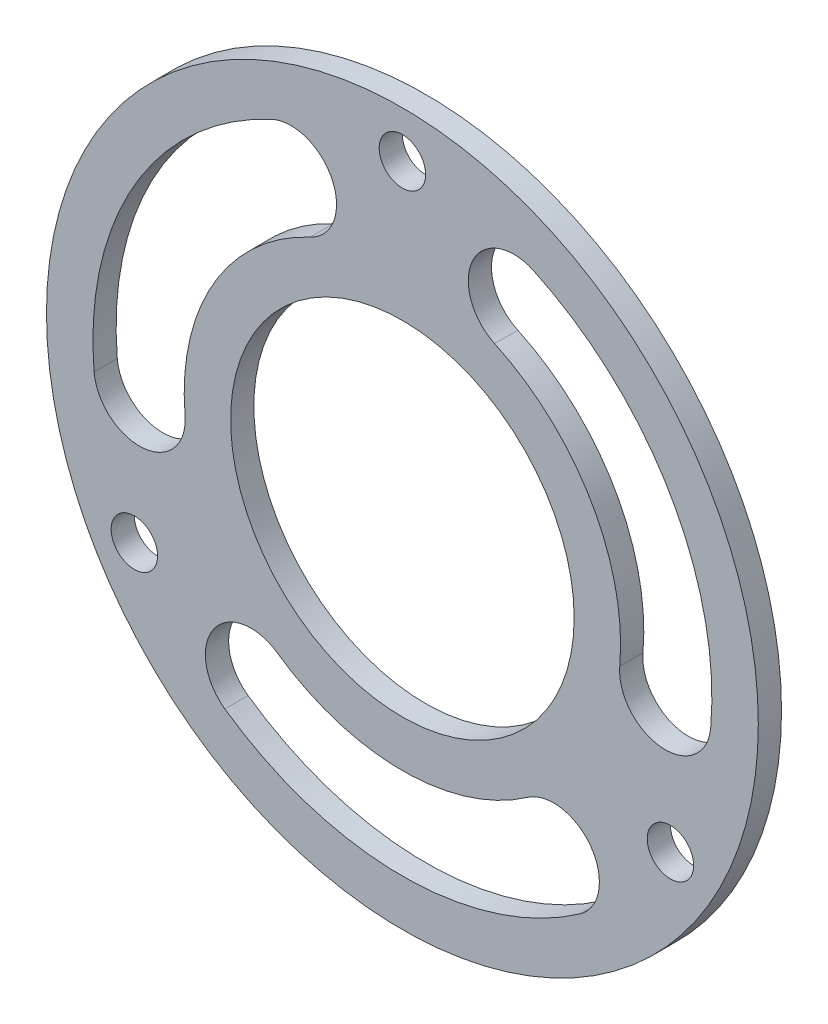
from build123d import *

# Parameters (mm, degrees)
SKETCH_1_R          = 23
SKETCH_1_R_2        = 1.5
SKETCH_1_R_3        = 11.1
EXTRUDE_1_DEPTH     = 1.5
CUT_EXTRUDE_1_DEPTH = 2.5


with BuildPart() as part:
    # 草图1 → 凸台-拉伸1 (new body)
    with BuildSketch(Plane.XY):
        Circle(SKETCH_1_R)
        with Locations((0, 20)):
            Circle(SKETCH_1_R_2, mode=Mode.SUBTRACT)
        Circle(SKETCH_1_R_3, mode=Mode.SUBTRACT)
        with Locations((17.320508076, -10)):
            Circle(SKETCH_1_R_2, mode=Mode.SUBTRACT)
        with Locations((-17.320508076, -10)):
            Circle(SKETCH_1_R_2, mode=Mode.SUBTRACT)
    extrude(amount=EXTRUDE_1_DEPTH)

    # 草图2 → 切除-拉伸1 (cut, through all)
    with BuildSketch(Plane.XY.offset(1.5)):
        with BuildLine():
            ThreePointArc((-8.452365235, 18.126155741), (-17.320508076, 10), (-19.923893962, -1.743114855))
            ThreePointArc((-19.923893962, -1.743114855), (-16.728010161, -4.424779773), (-14.046345243, -1.228895973))
            ThreePointArc((-14.046345243, -1.228895973), (-12.210958193, 7.05), (-5.958917491, 12.778939797))
            ThreePointArc((-5.958917491, 12.778939797), (-4.532033391, 16.699271641), (-8.452365235, 18.126155741))
        make_face()
        with BuildLine():
            ThreePointArc((19.923893962, -1.743114855), (17.320508076, 10), (8.452365235, 18.126155741))
            ThreePointArc((8.452365235, 18.126155741), (4.532033391, 16.699271641), (5.958917491, 12.778939797))
            ThreePointArc((5.958917491, 12.778939797), (12.210958193, 7.05), (14.046345243, -1.228895973))
            ThreePointArc((14.046345243, -1.228895973), (16.728010161, -4.424779773), (19.923893962, -1.743114855))
        make_face()
        with BuildLine():
            ThreePointArc((-11.471528727, -16.383040886), (0, -20), (11.471528727, -16.383040886))
            ThreePointArc((11.471528727, -16.383040886), (12.19597677, -12.274491868), (8.087427753, -11.550043824))
            ThreePointArc((8.087427753, -11.550043824), (0, -14.1), (-8.087427753, -11.550043824))
            ThreePointArc((-8.087427753, -11.550043824), (-12.19597677, -12.274491868), (-11.471528727, -16.383040886))
        make_face()
    extrude(amount=-CUT_EXTRUDE_1_DEPTH, mode=Mode.SUBTRACT)


solid = part.part
